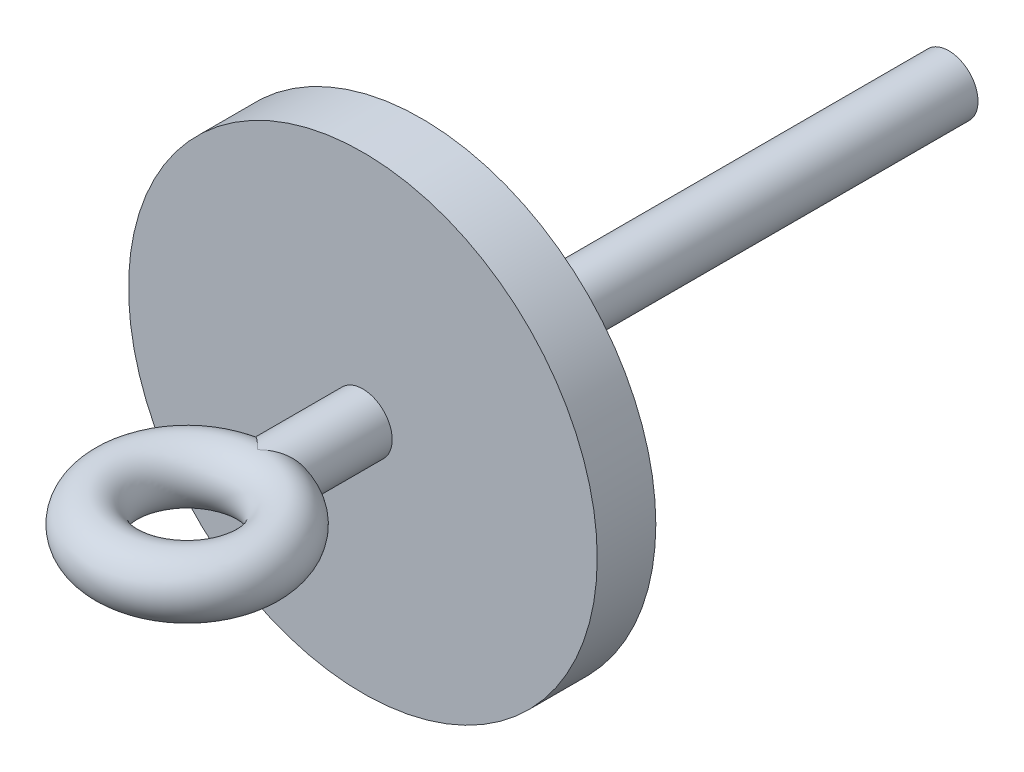
from build123d import *

# Parameters (mm, degrees)
SKETCH1_R                = 50.8
BOSS_EXTRUDE1_DEPTH      = 12.7
SKETCH2_R                = 6.35
BOSS_EXTRUDE2_DEPTH      = 114.3
BOSS_EXTRUDE2_DEPTH_BACK = 35.56
SKETCH4_R                = 6.35


with BuildPart() as part:
    # Sketch1 → Boss-Extrude1 (new body)
    with BuildSketch(Plane.XY):
        Circle(SKETCH1_R)
    extrude(amount=BOSS_EXTRUDE1_DEPTH)

    # Sketch2 → Boss-Extrude2 (add, two sides)
    with BuildSketch(Plane(origin=(0, 0, 0), x_dir=(-1, 0, 0), z_dir=(0, 0, -1))) as boss_extrude2_sk:
        Circle(SKETCH2_R)
    extrude(amount=BOSS_EXTRUDE2_DEPTH)
    extrude(boss_extrude2_sk.sketch, amount=-BOSS_EXTRUDE2_DEPTH_BACK)

    # Sweep3: sweep along a path in Sketch3
    with BuildLine(Plane(origin=(0, 0, 0), x_dir=(1, 0, 0), z_dir=(0, 1, 0))) as sweep3_path:
        ThreePointArc((0, -66.04), (15.24, -50.8), (0, -35.56))
    # Sketch4 → Sweep3 (sweep)
    with BuildSketch(Plane.XY.offset(50.8)):
        with Locations((15.298746374, 0)):
            Circle(SKETCH4_R)
    sweep3 = sweep(path=sweep3_path.line)

    # Mirror1: Sweep3 across plane
    add(sweep3.mirror(Plane(origin=(0, 0, 66.098746374), x_dir=(0, 0, 1), z_dir=(-1, 0, 0))))


solid = part.part
